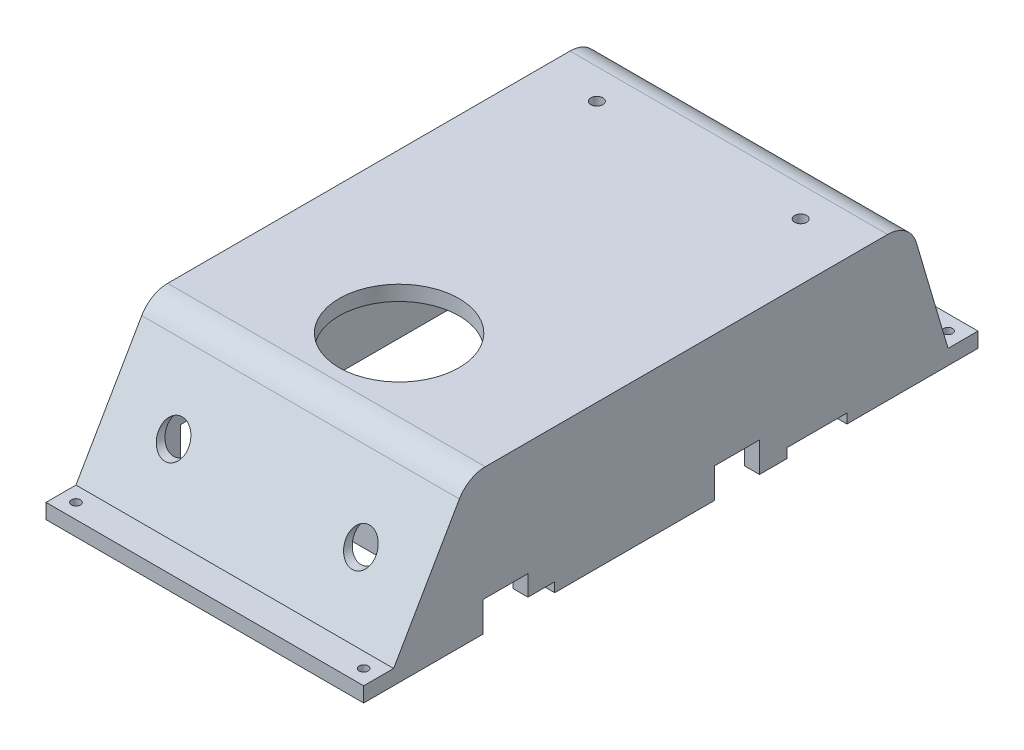
from build123d import *

# Parameters (mm, degrees)
SKETCH1_W                        = 156
SKETCH1_H                        = 260
BOSS_EXTRUDE1_DEPTH              = 10
BOSS_EXTRUDE2_DEPTH              = 66
SKETCH3_R                        = 40
CUT_EXTRUDE1_DEPTH               = 77
SKETCH4_W                        = 20
SKETCH4_H                        = 37.5
CUT_EXTRUDE2_DEPTH               = 5
SKETCH6_W                        = 15
SKETCH6_H                        = 15
BOSS_EXTRUDE3_DEPTH              = 10
SKETCH7_R                        = 4
CUT_EXTRUDE4_DEPTH               = 10
FILLET1_R                        = 2
SKETCH8_W                        = 156
SKETCH8_H                        = 10
BOSS_EXTRUDE4_DEPTH              = 10
SKETCH9_R                        = 4
CUT_EXTRUDE5_DEPTH               = 77
SKETCH10_W                       = 156
SKETCH10_H                       = 10
BOSS_EXTRUDE5_DEPTH              = 25
SKETCH11_W                       = 28
SKETCH11_H                       = 295
BOSS_EXTRUDE6_DEPTH              = 10
BOSS_EXTRUDE7_DEPTH              = 212
SKETCH13_R                       = 3
CUT_EXTRUDE6_DEPTH               = 11
BOSS_EXTRUDE10_DEPTH             = 212
SKETCH18_R                       = 3
CUT_EXTRUDE8_DEPTH               = 11
SKETCH19_R                       = 10
CUT_EXTRUDE9_DEPTH               = 113
BOSS_EXTRUDE11_REACH             = 47.35
SKETCH20_W                       = 10
SKETCH20_H                       = 86
BOSS_EXTRUDE11_DIRECTION_2_REACH = 366.652
FILLET2_R                        = 20
SKETCH21_R                       = 15
CUT_EXTRUDE11_DEPTH              = 5
SKETCH22_W                       = 30
SKETCH22_H                       = 20
CUT_EXTRUDE12_DEPTH              = 1
CUT_EXTRUDE12_DEPTH_BACK         = 213
SKETCH23_W                       = 40
SKETCH23_H                       = 6.35
CUT_EXTRUDE13_DEPTH              = 1
CUT_EXTRUDE13_DEPTH_BACK         = 213


with BuildPart() as part:
    # Sketch1 → Boss-Extrude1 (new body)
    with BuildSketch(Plane(origin=(0, 0, 0), x_dir=(1, 0, 0), z_dir=(0, 1, 0))):
        Rectangle(SKETCH1_W, SKETCH1_H)
    extrude(amount=BOSS_EXTRUDE1_DEPTH)

    # Sketch2 → Boss-Extrude2 (add)
    with BuildSketch(Plane.XZ):
        Polygon((-73, -120), (-73, 125), (73, 125), (73, -120), (78, -120), (78, 130), (-78, 130), (-78, -120), align=None)
    extrude(amount=BOSS_EXTRUDE2_DEPTH)

    # Sketch3 → Cut-Extrude1 (cut, through all)
    with BuildSketch(Plane(origin=(0, 10, 0), x_dir=(1, 0, 0), z_dir=(0, 1, 0))):
        with Locations((0, -70)):
            Circle(SKETCH3_R)
    extrude(amount=-CUT_EXTRUDE1_DEPTH, mode=Mode.SUBTRACT)

    # Sketch4 → Cut-Extrude2 (cut)
    with BuildSketch(Plane.XY.offset(130)):
        with Locations((-62.5, -47.25)):
            Rectangle(SKETCH4_W, SKETCH4_H)
        with Locations((62.5, -47.25)):
            Rectangle(SKETCH4_W, SKETCH4_H)
    extrude(amount=-CUT_EXTRUDE2_DEPTH, mode=Mode.SUBTRACT)

    # Sketch6 → Boss-Extrude3 (add)
    with BuildSketch(Plane.XZ.offset(66)):
        with Locations((0, 137.5)):
            Rectangle(SKETCH6_W, SKETCH6_H)
    extrude(amount=-BOSS_EXTRUDE3_DEPTH)

    # Sketch7 → Cut-Extrude4 (cut)
    with BuildSketch(Plane.XZ.offset(66)):
        with Locations((0, 137.5)):
            Circle(SKETCH7_R)
    extrude(amount=-CUT_EXTRUDE4_DEPTH, mode=Mode.SUBTRACT)

    # Fillet1
    fillet1_edges = [part.edges().sort_by_distance(p)[0] for p in [
        (7.5, -61, 145),
        (-7.5, -61, 145),
    ]]
    fillet(fillet1_edges, radius=FILLET1_R)

    # Sketch8 → Boss-Extrude4 (add)
    with BuildSketch(Plane(origin=(0, 0, -130), x_dir=(-1, 0, 0), z_dir=(0, 0, -1))):
        with Locations((0, 5)):
            Rectangle(SKETCH8_W, SKETCH8_H)
    extrude(amount=BOSS_EXTRUDE4_DEPTH)

    # Sketch9 → Cut-Extrude5 (cut, through all)
    with BuildSketch(Plane(origin=(0, 10, 0), x_dir=(1, 0, 0), z_dir=(0, 1, 0))):
        with Locations((-68, 130)):
            Circle(SKETCH9_R)
        with Locations((68, 130)):
            Circle(SKETCH9_R)
    extrude(amount=-CUT_EXTRUDE5_DEPTH, mode=Mode.SUBTRACT)

    # Sketch10 → Boss-Extrude5 (add)
    with BuildSketch(Plane(origin=(0, 0, -140), x_dir=(-1, 0, 0), z_dir=(0, 0, -1))):
        with Locations((0, 5)):
            Rectangle(SKETCH10_W, SKETCH10_H)
    extrude(amount=BOSS_EXTRUDE5_DEPTH)

    # Sketch11 → Boss-Extrude6 (add)
    with BuildSketch(Plane(origin=(0, 10, 0), x_dir=(1, 0, 0), z_dir=(0, 1, 0))):
        with Locations((-92, 17.5)):
            Rectangle(SKETCH11_W, SKETCH11_H)
        with Locations((92, 17.5)):
            Rectangle(SKETCH11_W, SKETCH11_H)
    extrude(amount=-BOSS_EXTRUDE6_DEPTH)

    # Sketch12 → Boss-Extrude7 (add)
    with BuildSketch(Plane.ZY.offset(106)):
        Polygon((-165, 0), (-190.349999035, -86), (-210.349999035, -86), (-210.349999035, -76), (-190.349999035, -76), (-165, 10), align=None)
    extrude(amount=-BOSS_EXTRUDE7_DEPTH)

    # Sketch13 → Cut-Extrude6 (cut, through all)
    with BuildSketch(Plane(origin=(0, -76, 0), x_dir=(1, 0, 0), z_dir=(0, 1, 0))):
        with Locations((-96, 200.349999035)):
            Circle(SKETCH13_R)
        with Locations((96, 200.349999035)):
            Circle(SKETCH13_R)
    extrude(amount=-CUT_EXTRUDE6_DEPTH, mode=Mode.SUBTRACT)

    # Sketch17 → Boss-Extrude10 (add)
    with BuildSketch(Plane(origin=(106, 0, 0), x_dir=(0, 0, -1), z_dir=(1, 0, 0))):
        Polygon((-130, 0), (-179.65212315, -86), (-199.65212315, -86), (-199.65212315, -76), (-179.65212315, -76), (-130, 10), align=None)
    extrude(amount=-BOSS_EXTRUDE10_DEPTH)

    # Sketch18 → Cut-Extrude8 (cut, through all)
    with BuildSketch(Plane(origin=(0, -76, 0), x_dir=(1, 0, 0), z_dir=(0, 1, 0))):
        with Locations((-96, -189.65212315)):
            Circle(SKETCH18_R)
        with Locations((96, -189.65212315)):
            Circle(SKETCH18_R)
    extrude(amount=-CUT_EXTRUDE8_DEPTH, mode=Mode.SUBTRACT)

    # Sketch19 → Cut-Extrude9 (cut)
    with BuildSketch(Plane.XY.offset(130)):
        with Locations((-62.5, -38.5)):
            Circle(SKETCH19_R)
        with Locations((62.5, -38.5)):
            Circle(SKETCH19_R)
    extrude(amount=CUT_EXTRUDE9_DEPTH, mode=Mode.SUBTRACT)

    # Boss-Extrude11: up to this face of the body (flat: up to its plane)
    boss_extrude11_end = Plane(part.part.faces().sort_by_distance((0, -33, -177.674999518))[0])
    # Sketch20 → Boss-Extrude11 (add, up to the picked face)
    with BuildSketch(Plane(origin=(0, 0, -165), x_dir=(-1, 0, 0), z_dir=(0, 0, -1)), mode=Mode.PRIVATE) as boss_extrude11_sk1:
        with Locations((-101, -43)):
            Rectangle(SKETCH20_W, SKETCH20_H)
    boss_extrude11_tool1 = split(extrude(boss_extrude11_sk1.sketch, amount=BOSS_EXTRUDE11_REACH, mode=Mode.PRIVATE), bisect_by=boss_extrude11_end, keep=Keep.BOTH, mode=Mode.PRIVATE)
    add(boss_extrude11_tool1.solids().sort_by_distance((101, -43, -165))[0])
    # Sketch20 → Boss-Extrude11 (add, up to the picked face)
    with BuildSketch(Plane(origin=(0, 0, -165), x_dir=(-1, 0, 0), z_dir=(0, 0, -1)), mode=Mode.PRIVATE) as boss_extrude11_sk2:
        with Locations((101, -43)):
            Rectangle(SKETCH20_W, SKETCH20_H)
    boss_extrude11_tool2 = split(extrude(boss_extrude11_sk2.sketch, amount=BOSS_EXTRUDE11_REACH, mode=Mode.PRIVATE), bisect_by=boss_extrude11_end, keep=Keep.BOTH, mode=Mode.PRIVATE)
    add(boss_extrude11_tool2.solids().sort_by_distance((-101, -43, -165))[0])

    # Sketch20 → Boss-Extrude11 direction 2 (add, up to next)
    with BuildSketch(Plane(origin=(0, 0, -165), x_dir=(-1, 0, 0), z_dir=(0, 0, -1)), mode=Mode.PRIVATE) as boss_extrude11_direction_2_sk1:
        with Locations((-101, -43)):
            Rectangle(SKETCH20_W, SKETCH20_H)
    boss_extrude11_direction_2_tool1 = extrude(boss_extrude11_direction_2_sk1.sketch, amount=-BOSS_EXTRUDE11_DIRECTION_2_REACH, mode=Mode.PRIVATE) - part.part
    add(boss_extrude11_direction_2_tool1.solids().sort_by_distance((101, -43, -165))[0])
    # Sketch20 → Boss-Extrude11 direction 2 (add, up to next)
    with BuildSketch(Plane(origin=(0, 0, -165), x_dir=(-1, 0, 0), z_dir=(0, 0, -1)), mode=Mode.PRIVATE) as boss_extrude11_direction_2_sk2:
        with Locations((101, -43)):
            Rectangle(SKETCH20_W, SKETCH20_H)
    boss_extrude11_direction_2_tool2 = extrude(boss_extrude11_direction_2_sk2.sketch, amount=-BOSS_EXTRUDE11_DIRECTION_2_REACH, mode=Mode.PRIVATE) - part.part
    add(boss_extrude11_direction_2_tool2.solids().sort_by_distance((-101, -43, -165))[0])

    # Fillet2
    fillet2_edges = [part.edges().sort_by_distance(p)[0] for p in [
        (0, 10, -165),
        (0, 10, 130),
    ]]
    fillet(fillet2_edges, radius=FILLET2_R)

    # Sketch21 → Cut-Extrude11 (cut)
    with BuildSketch(Plane(origin=(78, 0, 0), x_dir=(0, 0, -1), z_dir=(1, 0, 0))):
        with Locations((90, -30.5)):
            Circle(SKETCH21_R)
    extrude(amount=-CUT_EXTRUDE11_DEPTH, mode=Mode.SUBTRACT)

    # Sketch22 → Cut-Extrude12 (cut, two sides)
    with BuildSketch(Plane(origin=(106, 0, 0), x_dir=(0, 0, -1), z_dir=(1, 0, 0))) as cut_extrude12_sk:
        with Locations((-105, -76)):
            Rectangle(SKETCH22_W, SKETCH22_H)
        with Locations((49.5, -76)):
            Rectangle(SKETCH22_W, SKETCH22_H)
    extrude(amount=CUT_EXTRUDE12_DEPTH, mode=Mode.SUBTRACT)
    extrude(cut_extrude12_sk.sketch, amount=-CUT_EXTRUDE12_DEPTH_BACK, mode=Mode.SUBTRACT)

    # Sketch23 → Cut-Extrude13 (cut, two sides)
    with BuildSketch(Plane.ZY.offset(106)) as cut_extrude13_sk:
        with Locations((-102.849999035, -82.825)):
            Rectangle(SKETCH23_W, SKETCH23_H)
        with Locations((92.150000965, -82.825)):
            Rectangle(SKETCH23_W, SKETCH23_H)
    extrude(amount=CUT_EXTRUDE13_DEPTH, mode=Mode.SUBTRACT)
    extrude(cut_extrude13_sk.sketch, amount=-CUT_EXTRUDE13_DEPTH_BACK, mode=Mode.SUBTRACT)


solid = part.part
